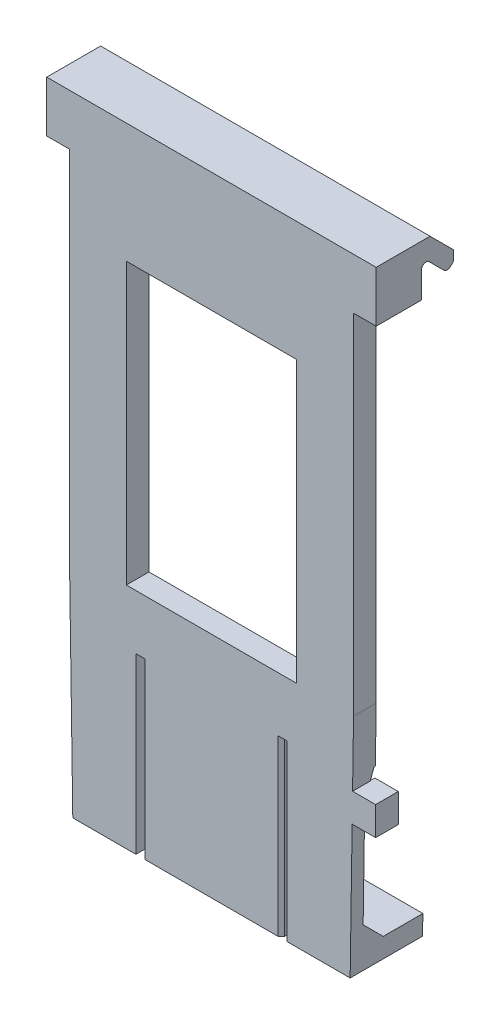
from build123d import *
from OCP.BRepFilletAPI import BRepFilletAPI_MakeChamfer

# Parameters (mm, degrees)
BOSS_EXTRUDE1_START  = 2
SKETCH1_W            = 17.5768
SKETCH1_H            = 31.241999999999997
SKETCH1_W_2          = 15.036799999999998
SKETCH1_H_2          = 24.764999999999997
BOSS_EXTRUDE1_DEPTH  = 2
BOSS_EXTRUDE2_START  = 2
BOSS_EXTRUDE2_DEPTH  = 29.09
BOSS_EXTRUDE3_DEPTH  = 1.5
BOSS_EXTRUDE4_DEPTH  = 13.843
BOSS_EXTRUDE5_DEPTH  = 1.095
BOSS_EXTRUDE6_DEPTH  = 1.095
BOSS_EXTRUDE7_DEPTH  = 2
CHAMFER1_SIZE        = 2.3
CHAMFER1_SIZE2       = 0.8
BOSS_EXTRUDE9_DEPTH  = 5.299999999999998
CHAMFER2_SIZE        = 1.8
CUT_EXTRUDE1_DEPTH   = 0.25
CUT_EXTRUDE2_DEPTH   = 0.25
CUT_EXTRUDE3_REACH   = 62.791
SKETCH15_W           = 2.073672467648368
SKETCH15_H           = 2.532
BOSS_EXTRUDE10_DEPTH = 2
CHAMFER3_SIZE        = 0.3
CHAMFER4_SIZE        = 2


with BuildPart() as part:
    # Sketch1 → Boss-Extrude1 (new body)
    with BuildSketch(Plane.XY.offset(BOSS_EXTRUDE1_START)):
        with Locations((12.544999999999998, 29.464000000000002)):
            Rectangle(SKETCH1_W, SKETCH1_H)
        with Locations((12.544999999999998, 31.051499999999997)):
            Rectangle(SKETCH1_W_2, SKETCH1_H_2, mode=Mode.SUBTRACT)
    extrude(amount=BOSS_EXTRUDE1_DEPTH)



with BuildPart() as body_2:
    # Sketch2 → Boss-Extrude2 (new body)
    with BuildSketch(Plane(origin=(25.09, 5.28e-15, 0), x_dir=(0, 0, -1), z_dir=(1, 2.1e-16, 0)).offset(BOSS_EXTRUDE2_START)):
        with BuildLine():
            Line((0, 51.489999999999995), (2.4e-16, 49.489999999999995))
            Line((2.4e-16, 49.489999999999995), (-4, 49.489999999999995))
            Line((-4, 49.489999999999995), (-4.000000000000001, 53.99431457505075))
            Line((-4.000000000000001, 53.99431457505075), (0.7579894972000346, 53.99431457505075))
            Line((0.7579894972000346, 53.99431457505075), (2.805084072136604, 51.947220000114164))
            Line((2.805084072136604, 51.947220000114164), (2.805084072136603, 51.02508407213661))
            Line((2.805084072136603, 51.02508407213661), (2.552842712474611, 50.77284271247461))
            ThreePointArc((2.552842712474611, 50.77284271247461), (2.2699999999999894, 50.65568542494923), (1.9871572875253678, 50.77284271247461))
            Line((1.9871572875253678, 50.77284271247461), (1.27, 51.489999999999995))
            Line((1.27, 51.489999999999995), (0.6828427124746198, 52.07715728752538))
            ThreePointArc((0.6828427124746198, 52.07715728752538), (0.24692662705396132, 52.163866388055276), (0, 51.794314575050755))
            Line((0, 51.794314575050755), (0, 51.489999999999995))
        make_face()
    extrude(amount=-BOSS_EXTRUDE2_DEPTH)


with BuildPart() as body_3:
    # Sketch4 → Boss-Extrude3 (new body)
    with BuildSketch(Plane.XZ):
        Polygon((6.374999999999999, 4), (18.715, 4), (18.715, -1.7), (6.374999999999999, -1.699999999999999), align=None)
        with BuildLine():
            Line((17.215, 1.2499999999999993), (17.214999999999996, 1.96))
            ThreePointArc((17.214999999999996, 1.96), (16.79030483272049, 2.985304832720491), (15.765, 3.409999999999999))
            Line((15.765, 3.409999999999999), (9.325, 3.41))
            ThreePointArc((9.325, 3.41), (8.299695167279506, 2.985304832720494), (7.875, 1.96))
            Line((7.875, 1.96), (7.874999999999998, 1.2499999999999998))
            ThreePointArc((7.874999999999998, 1.2499999999999998), (8.299695167279504, 0.22469516727950523), (9.325, -0.20000000000000095))
            Line((9.325, -0.20000000000000095), (15.765, -0.19999999999999923))
            ThreePointArc((15.765, -0.19999999999999923), (16.790304832720494, 0.22469516727950656), (17.215, 1.2499999999999993))
        make_face(mode=Mode.SUBTRACT)
    extrude(amount=BOSS_EXTRUDE3_DEPTH)


with BuildPart() as part_1:
    add(part.part)

    add(body_3.part)  # Boss-Extrude4 merges body 3
    # Sketch5 → Boss-Extrude4 (add)
    with BuildSketch(Plane(origin=(0, 0, 0), x_dir=(1, 1.4e-16, 0), z_dir=(-1.4e-16, 1, 0))):
        with BuildLine():
            ThreePointArc((9.325, -3.41), (8.31393620379325, -2.9993507588874895), (7.875551829143242, -2))
            Line((7.875551829143242, -2), (6.374999999999999, -2))
            Line((6.374999999999999, -2), (6.374999999999999, -4))
            Line((6.375, -4), (18.715, -4))
            Line((18.715, -4), (18.715, -2))
            Line((18.715, -2), (17.214448170856755, -2))
            ThreePointArc((17.214448170856755, -2), (16.77606379620675, -2.9993507588874895), (15.765, -3.4099999999999993))
            Line((15.765, -3.409999999999999), (9.325, -3.4099999999999997))
        make_face()
    extrude(amount=BOSS_EXTRUDE4_DEPTH)

    # Sketch6 → Boss-Extrude5 (add)
    with BuildSketch(Plane.XY.offset(2.905)):
        Polygon((6.1249999999999964, 13.843), (6.124999999999998, -1.4999999999999991), (1.821e-14, -1.5), (1.431e-14, 13.843), align=None)
    extrude(amount=BOSS_EXTRUDE5_DEPTH)

    # Sketch9 → Boss-Extrude6 (add)
    with BuildSketch(Plane.XY.offset(2.905)):
        Polygon((18.965, 13.843), (25.09, 13.843), (25.09, -1.4999999999999973), (18.965000000000003, -1.4999999999999973), align=None)
    extrude(amount=BOSS_EXTRUDE6_DEPTH)


    add(body_2.part)  # Boss-Extrude7 merges body 2
    # Sketch10 → Boss-Extrude7 (add)
    with BuildSketch(Plane.XY.offset(4)):
        Polygon((25.09, 49.489999999999995), (25.09, 13.843), (21.333399999999997, 13.843), (21.333399999999997, 45.085), (3.7566, 45.085), (3.7566, 13.843), (1.431e-14, 13.843), (-8.67e-15, 49.489999999999995), align=None)
    extrude(amount=-BOSS_EXTRUDE7_DEPTH)

    # Chamfer1: one chamfer whose edges measure the first distance from different faces: ONE call of the kernel's chamfer builder (chamfer() names one face for all edges)
    chamfer1_edges_1 = [part_1.edges().sort_by_distance(p)[0] for p in [
        (22.0275, 13.843, 2.905),
    ]]
    chamfer1_side_1 = [part_1.faces().sort_by_distance(p)[0] for p in [
        (22.0275, 6.171500000000002, 2.905),
    ]]
    chamfer1_edges_2 = [part_1.edges().sort_by_distance(p)[0] for p in [
        (3.0625000000000053, 13.843, 2.905),
    ]]
    chamfer1_side_2 = [part_1.faces().sort_by_distance(p)[0] for p in [
        (3.0625000000000067, 6.1715, 2.9050000000000002),
    ]]
    chamfer1 = BRepFilletAPI_MakeChamfer(part_1.part.solid().wrapped)
    for e in chamfer1_edges_1:
        chamfer1.Add(CHAMFER1_SIZE, CHAMFER1_SIZE2, e.wrapped, chamfer1_side_1[0].wrapped)  # the first distance lies on this face
    for e in chamfer1_edges_2:
        chamfer1.Add(CHAMFER1_SIZE, CHAMFER1_SIZE2, e.wrapped, chamfer1_side_2[0].wrapped)  # the first distance lies on this face
    add(Compound.cast(chamfer1.Shape()), mode=Mode.REPLACE)

    # Sketch11 → Boss-Extrude9 (add)
    with BuildSketch(Plane(origin=(0, 0, 2.905), x_dir=(-1, 0, 0), z_dir=(0, 0, -1))):
        Polygon((-6.124999999999998, -1.4999999999999991), (-1.779e-14, -1.4999999999999991), (-1.49e-14, 0.2500000000000002), (-6.124999999999998, 0.2500000000000009), align=None)
        Polygon((-18.965000000000003, -1.4999999999999973), (-25.09, -1.4999999999999973), (-25.09, 0.25000000000000194), (-18.965000000000003, 0.25000000000000266), align=None)
    extrude(amount=BOSS_EXTRUDE9_DEPTH)

    # Chamfer2
    chamfer2_edges = [part_1.edges().sort_by_distance(p)[0] for p in [
        (3.0625000000000067, 0.25000000000000056, 2.905),
        (22.027500000000003, 0.2500000000000023, 2.905),
    ]]
    chamfer(chamfer2_edges, length=CHAMFER2_SIZE)

    # Sketch12 → Cut-Extrude1 (cut)
    with BuildSketch(Plane(origin=(6.124999999999998, 6.9e-16, 0), x_dir=(0, 0, -1), z_dir=(1, 1.1e-16, 0))):
        Polygon((-4, 13.843), (-4, -1.4999999999999998), (2.3949999999999987, -1.4999999999999998), (2.3949999999999987, 0.25000000000000017), (-1.1049999999999898, 0.25000000000000017), (-2.905, 2.0499999999999883), (-2.905, 11.543000000000012), (-2.104999999999996, 13.843), align=None)
    extrude(amount=-CUT_EXTRUDE1_DEPTH, mode=Mode.SUBTRACT)

    # Sketch13 → Cut-Extrude2 (cut)
    with BuildSketch(Plane.ZY.offset(-18.965000000000003)):
        Polygon((4, -1.5000000000000018), (4, 13.842999999999996), (2.104999999999996, 13.842999999999996), (2.905, 11.543000000000008), (2.905, 2.04999999999999), (1.1049999999999898, 0.2499999999999984), (-2.3949999999999987, 0.2499999999999984), (-2.3949999999999987, -1.5000000000000018), align=None)
    extrude(amount=-CUT_EXTRUDE2_DEPTH, mode=Mode.SUBTRACT)

    # Cut-Extrude3: up to this face of the body (flat: up to its plane)
    cut_extrude3_end = Plane(part_1.part.faces().sort_by_distance((2.9375, -0.625, -2.395))[0])
    # Sketch14 → Cut-Extrude3 (cut, up to the picked face)
    with BuildSketch(Plane.XY.offset(3.9999999999999907), mode=Mode.PRIVATE) as cut_extrude3_sk1:
        Polygon((25.09, 18.669), (24.79, -1.4999999999999967), (25.09, -1.4999999999999967), align=None)
    cut_extrude3_tool1 = split(extrude(cut_extrude3_sk1.sketch, amount=-CUT_EXTRUDE3_REACH, mode=Mode.PRIVATE), bisect_by=cut_extrude3_end, keep=Keep.BOTH, mode=Mode.PRIVATE)
    # Sketch14 → Cut-Extrude3 (cut, up to the picked face)
    with BuildSketch(Plane.XY.offset(3.9999999999999907), mode=Mode.PRIVATE) as cut_extrude3_sk2:
        Polygon((-1.119e-14, 18.669755162923135), (0.3000000000000182, -1.4999999999999993), (1.821e-14, -1.4999999999999991), align=None)
    cut_extrude3_tool2 = split(extrude(cut_extrude3_sk2.sketch, amount=-CUT_EXTRUDE3_REACH, mode=Mode.PRIVATE), bisect_by=cut_extrude3_end, keep=Keep.BOTH, mode=Mode.PRIVATE)
    add(cut_extrude3_tool1.solids().sort_by(Axis((24.99, 5.223, 4), (0, 0, -1)))[0], mode=Mode.SUBTRACT)
    add(cut_extrude3_tool2.solids().sort_by(Axis((0.1, 5.223252, 4), (0, 0, -1)))[0], mode=Mode.SUBTRACT)

    # Sketch15 → Boss-Extrude10 (add)
    with BuildSketch(Plane.XY.offset(3.9999999999999907)):
        with Locations((26.00316376617581, 11.620500000000002)):
            Rectangle(SKETCH15_W, SKETCH15_H)
    extrude(amount=-BOSS_EXTRUDE10_DEPTH)

    # Chamfer3
    chamfer3_edges = [part_1.edges().sort_by_distance(p)[0] for p in [
        (6.374999999999998, 6.171500000000002, 4),
        (18.714999999999996, 6.171500000000003, 4),
    ]]
    chamfer(chamfer3_edges, length=CHAMFER3_SIZE)

    # Chamfer4
    chamfer4_edges = [part_1.edges().sort_by_distance(p)[0] for p in [
        (7.1252759145716205, 1e-15, 2),
        (17.96472408542838, 2.53e-15, 2),
    ]]
    chamfer(chamfer4_edges, length=CHAMFER4_SIZE)


solid = part_1.part
